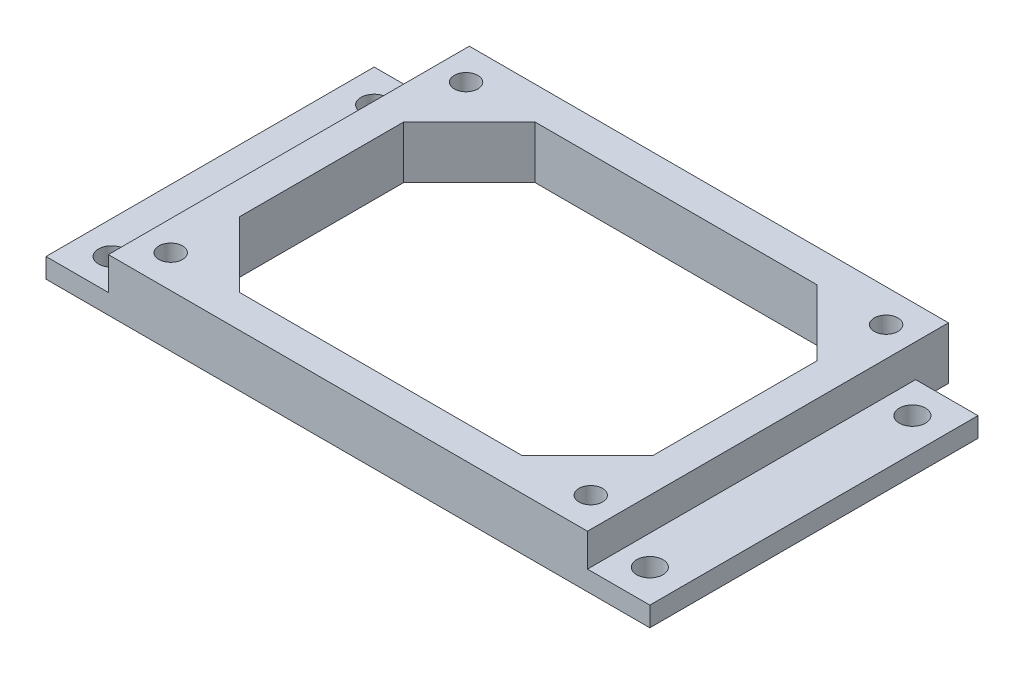
from build123d import *

# Parameters (mm, degrees)
SKETCH1_W                = 73
SKETCH1_H                = 50
BOSS_EXTRUDE1_DEPTH      = 5
SKETCH2_W                = 92
SKETCH2_H                = 50
BOSS_EXTRUDE2_DEPTH      = 3
M3_CLEARANCE_HOLE1_D     = 4
M3_CLEARANCE_HOLE1_DEPTH = 10
M3_CLEARANCE_HOLE1_TIP   = 1.201721238
SKETCH9_W                = 73
SKETCH9_H                = 8
BOSS_EXTRUDE3_DEPTH      = 5
M3_CLEARANCE_HOLE3_D     = 3.6
M3_CLEARANCE_HOLE3_DEPTH = 10
M3_CLEARANCE_HOLE3_TIP   = 1.081549114
CUT_EXTRUDE1_DEPTH       = 9


with BuildPart() as part:
    # Sketch1 → Boss-Extrude1 (new body)
    with BuildSketch(Plane(origin=(0, 0, 0), x_dir=(1, 0, 0), z_dir=(0, 1, 0))):
        Rectangle(SKETCH1_W, SKETCH1_H)
    extrude(amount=BOSS_EXTRUDE1_DEPTH)

    # Sketch2 → Boss-Extrude2 (add)
    with BuildSketch(Plane.XZ):
        Rectangle(SKETCH2_W, SKETCH2_H)
    extrude(amount=BOSS_EXTRUDE2_DEPTH)

    # M3 Clearance Hole1
    with Locations(Plane(origin=(0, 0, 0), x_dir=(1, 0, 0), z_dir=(0, 1, 0))):
        with Locations((-41, 20), (-41, -20), (41, 20), (41, -20)):
            Hole(M3_CLEARANCE_HOLE1_D / 2, depth=M3_CLEARANCE_HOLE1_DEPTH)
            with Locations((0, 0, -(M3_CLEARANCE_HOLE1_DEPTH + M3_CLEARANCE_HOLE1_TIP / 2))):  # 118° drill point
                Cone(0, M3_CLEARANCE_HOLE1_D / 2, M3_CLEARANCE_HOLE1_TIP, mode=Mode.SUBTRACT)

    # Sketch9 → Boss-Extrude3 (add)
    with BuildSketch(Plane(origin=(0, 0, -25), x_dir=(-1, 0, 0), z_dir=(0, 0, -1))):
        with Locations((0, 1)):
            Rectangle(SKETCH9_W, SKETCH9_H)
    extrude(amount=BOSS_EXTRUDE3_DEPTH)

    # M3 Clearance Hole3
    with Locations(Plane(origin=(0, 5, 0), x_dir=(1, 0, 0), z_dir=(0, 1, 0))):
        with Locations((32, -20), (-32, 25), (32, 25), (-32, -20)):
            Hole(M3_CLEARANCE_HOLE3_D / 2, depth=M3_CLEARANCE_HOLE3_DEPTH)
            with Locations((0, 0, -(M3_CLEARANCE_HOLE3_DEPTH + M3_CLEARANCE_HOLE3_TIP / 2))):  # 118° drill point
                Cone(0, M3_CLEARANCE_HOLE3_D / 2, M3_CLEARANCE_HOLE3_TIP, mode=Mode.SUBTRACT)

    # Sketch12 → Cut-Extrude1 (cut, through all)
    with BuildSketch(Plane(origin=(0, 5, 0), x_dir=(1, 0, 0), z_dir=(0, 1, 0))):
        Polygon((21.5, -20), (31.5, -10), (31.5, 15), (21.5, 25), (-21.5, 25), (-31.5, 15), (-31.5, -10), (-21.5, -20), align=None)
    extrude(amount=-CUT_EXTRUDE1_DEPTH, mode=Mode.SUBTRACT)


solid = part.part
